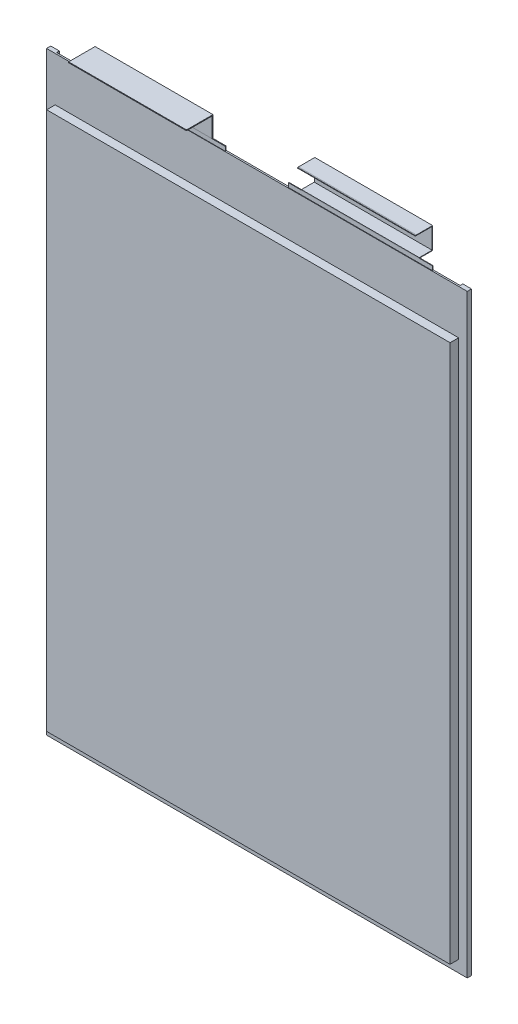
from build123d import *

# Parameters (mm, degrees)
SKETCH1_W                    = 160.6
SKETCH1_H                    = 227
INSULATION_DEPTH             = 0.3
INSULATION_DEPTH_BACK        = 0.3
SKETCH2_W                    = 154
SKETCH2_H                    = 205.5
MAIN_BODY_DEPTH              = 3.55
MAIN_BODY_DEPTH_BACK         = 3.55
SIDE_FOLDS_DEPTH             = 1.016
SKETCH6_W                    = 55
SKETCH6_H                    = 18.6
NEGATIVE_TAB_BASE_DEPTH      = 0.1
NEGATIVE_TAB_BASE_DEPTH_BACK = 0.1
SKETCH7_W                    = 55
SKETCH7_H                    = 18.6
POSITIVE_TAB_BASE_DEPTH      = 0.15
POSITIVE_TAB_BASE_DEPTH_BACK = 0.15
SKETCH110_W                  = 0.3
SKETCH110_H                  = 45
POSITIVE_TAB_DEPTH           = 31.210499994
SKETCH110_ON_SEGMENT_2_W     = 0.3
SKETCH110_ON_SEGMENT_2_H     = 45
POSITIVE_TAB_2_DEPTH         = 33.469099994
SKETCH113_W                  = 0.2
SKETCH113_H                  = 45
NEGATIVE_TAB_DEPTH           = 23.600222221
SKETCH113_ON_SEGMENT_2_W     = 0.2
SKETCH113_ON_SEGMENT_2_H     = 45
NEGATIVE_TAB_2_DEPTH         = 51.904294442
SKETCH113_ON_SEGMENT_3_W     = 0.2
SKETCH113_ON_SEGMENT_3_H     = 45
NEGATIVE_TAB_3_DEPTH         = 55.060444442
SKETCH113_ON_SEGMENT_4_W     = 0.2
SKETCH113_ON_SEGMENT_4_H     = 45
NEGATIVE_TAB_4_DEPTH         = 30.622297221
SKETCH113_ON_SEGMENT_5_W     = 0.2
SKETCH113_ON_SEGMENT_5_H     = 45
NEGATIVE_TAB_5_DEPTH         = 1.4


with BuildPart() as part:
    # Sketch1 → Insulation (new, two sides)
    with BuildSketch(Plane.XY) as insulation_sk:
        Rectangle(SKETCH1_W, SKETCH1_H)
    extrude(amount=INSULATION_DEPTH)
    extrude(insulation_sk.sketch, amount=-INSULATION_DEPTH_BACK)

    # Sketch2 → Main Body (add, two sides)
    with BuildSketch(Plane.XY) as main_body_sk:
        with Locations((0, -6.25)):
            Rectangle(SKETCH2_W, SKETCH2_H)
    extrude(amount=MAIN_BODY_DEPTH)
    extrude(main_body_sk.sketch, amount=-MAIN_BODY_DEPTH_BACK)

    # Sketch5 → Side Folds (add)
    with BuildSketch(Plane(origin=(0, 0, -0.3), x_dir=(-1, 0, 0), z_dir=(0, 0, -1))):
        Polygon((-77, -109), (-77, 96.5), (-77, 113.5), (-80.3, 113.5), (-80.3, -113.5), (-77, -113.5), align=None)
        Polygon((77, 113.5), (77, 96.5), (77, -109), (77, -113.5), (80.3, -113.5), (80.3, 113.5), align=None)
    extrude(amount=SIDE_FOLDS_DEPTH)

    # Sketch6 → Negative Tab Base (add, two sides)
    with BuildSketch(Plane.XY) as negative_tab_base_sk:
        with Locations((39.3, 105.8)):
            Rectangle(SKETCH6_W, SKETCH6_H)
    extrude(amount=NEGATIVE_TAB_BASE_DEPTH)
    extrude(negative_tab_base_sk.sketch, amount=-NEGATIVE_TAB_BASE_DEPTH_BACK)

    # Sketch7 → Positive Tab Base (add, two sides)
    with BuildSketch(Plane.XY) as positive_tab_base_sk:
        with Locations((-39.7, 105.8)):
            Rectangle(SKETCH7_W, SKETCH7_H)
    extrude(amount=POSITIVE_TAB_BASE_DEPTH)
    extrude(positive_tab_base_sk.sketch, amount=-POSITIVE_TAB_BASE_DEPTH_BACK)


with BuildPart() as body_2:
    # Sketch110 → Positive Tab (new body)
    with BuildSketch(Plane(origin=(-39.7, 115.1, 0), x_dir=(0, 0, -1), z_dir=(0, 1, 0))):
        Rectangle(SKETCH110_W, SKETCH110_H)
    extrude(amount=POSITIVE_TAB_DEPTH)

    # Positive Tab mitre 1
    split(bisect_by=Plane(origin=(-39.7, 122.81, 0), x_dir=(1, 0, 0), z_dir=(0, -0.707106781, -0.707106781)), keep=Keep.TOP)


with BuildPart() as body_3:
    # Sketch110 on segment 2 (carried to segment 2) → Positive Tab 2 (new body)
    with BuildSketch(Plane(origin=(-39.7, 122.81, -23.500499994), x_dir=(0, 1, 0), z_dir=(0, 0, 1))):
        Rectangle(SKETCH110_ON_SEGMENT_2_W, SKETCH110_ON_SEGMENT_2_H)
    extrude(amount=POSITIVE_TAB_2_DEPTH)

    # Positive Tab 2 mitre 1
    split(bisect_by=Plane(origin=(-39.7, 122.81, 0), x_dir=(-1, 0, 0), z_dir=(0, 0.707106781, 0.707106781)), keep=Keep.TOP)


with BuildPart() as body_4:
    # Sketch113 → Negative Tab (new body)
    with BuildSketch(Plane(origin=(39.3, 115.1, 0), x_dir=(0, 0, -1), z_dir=(0, 1, 0))):
        Rectangle(SKETCH113_W, SKETCH113_H)
    extrude(amount=NEGATIVE_TAB_DEPTH)

    # Negative Tab mitre 1
    split(bisect_by=Plane(origin=(39.3, 115.2, 0), x_dir=(1, 0, 0), z_dir=(0, -0.707106781, 0.707106781)), keep=Keep.TOP)


with BuildPart() as body_5:
    # Sketch113 on segment 2 (carried to segment 2) → Negative Tab 2 (new body)
    with BuildSketch(Plane(origin=(39.3, 115.2, 23.500222221), x_dir=(0, -1, 0), z_dir=(0, 0, -1))):
        Rectangle(SKETCH113_ON_SEGMENT_2_W, SKETCH113_ON_SEGMENT_2_H)
    extrude(amount=NEGATIVE_TAB_2_DEPTH)

    # Negative Tab 2 mitre 1
    split(bisect_by=Plane(origin=(39.3, 115.2, 0), x_dir=(-1, 0, 0), z_dir=(0, 0.707106781, -0.707106781)), keep=Keep.TOP)

    # Negative Tab 2 mitre 2
    split(bisect_by=Plane(origin=(39.3, 115.2, -4.90385), x_dir=(1, 0, 0), z_dir=(0, -0.707106781, 0.707106781)), keep=Keep.TOP)


with BuildPart() as body_6:
    # Sketch113 on segment 3 (carried to segment 3) → Negative Tab 3 (new body)
    with BuildSketch(Plane(origin=(39.3, 91.699777779, -4.90385), x_dir=(0, 0, -1), z_dir=(0, 1, 0))):
        Rectangle(SKETCH113_ON_SEGMENT_3_W, SKETCH113_ON_SEGMENT_3_H)
    extrude(amount=NEGATIVE_TAB_3_DEPTH)

    # Negative Tab 3 mitre 1
    split(bisect_by=Plane(origin=(39.3, 115.2, -4.90385), x_dir=(-1, 0, 0), z_dir=(0, 0.707106781, -0.707106781)), keep=Keep.TOP)

    # Negative Tab 3 mitre 2
    split(bisect_by=Plane(origin=(39.3, 123.26, -4.90385), x_dir=(1, 0, 0), z_dir=(0, -0.707106781, -0.707106781)), keep=Keep.TOP)


with BuildPart() as body_7:
    # Sketch113 on segment 4 (carried to segment 4) → Negative Tab 4 (new body)
    with BuildSketch(Plane(origin=(39.3, 123.26, -28.404072221), x_dir=(0, 1, 0), z_dir=(0, 0, 1))):
        Rectangle(SKETCH113_ON_SEGMENT_4_W, SKETCH113_ON_SEGMENT_4_H)
    extrude(amount=NEGATIVE_TAB_4_DEPTH)

    # Negative Tab 4 mitre 1
    split(bisect_by=Plane(origin=(39.3, 123.26, -4.90385), x_dir=(-1, 0, 0), z_dir=(0, 0.707106781, 0.707106781)), keep=Keep.TOP)

    # Negative Tab 4 mitre 2
    split(bisect_by=Plane(origin=(39.3, 123.26, 1.218225), x_dir=(0, 1, 0), z_dir=(0, 0, -1)), keep=Keep.TOP)


with BuildPart() as body_8:
    # Sketch113 on segment 5 (carried to segment 5) → Negative Tab 5 (new body)
    with BuildSketch(Plane(origin=(39.3, 123.26, 0.218225), x_dir=(0, 1, 0), z_dir=(0, 0, 1))):
        Rectangle(SKETCH113_ON_SEGMENT_5_W, SKETCH113_ON_SEGMENT_5_H)
    extrude(amount=NEGATIVE_TAB_5_DEPTH)

    # Negative Tab 5 mitre 1
    split(bisect_by=Plane(origin=(39.3, 123.26, 1.218225), x_dir=(0, -1, 0), z_dir=(0, 0, 1)), keep=Keep.TOP)


solid = Compound([part.part, body_2.part, body_3.part, body_4.part, body_5.part, body_6.part, body_7.part, body_8.part])
